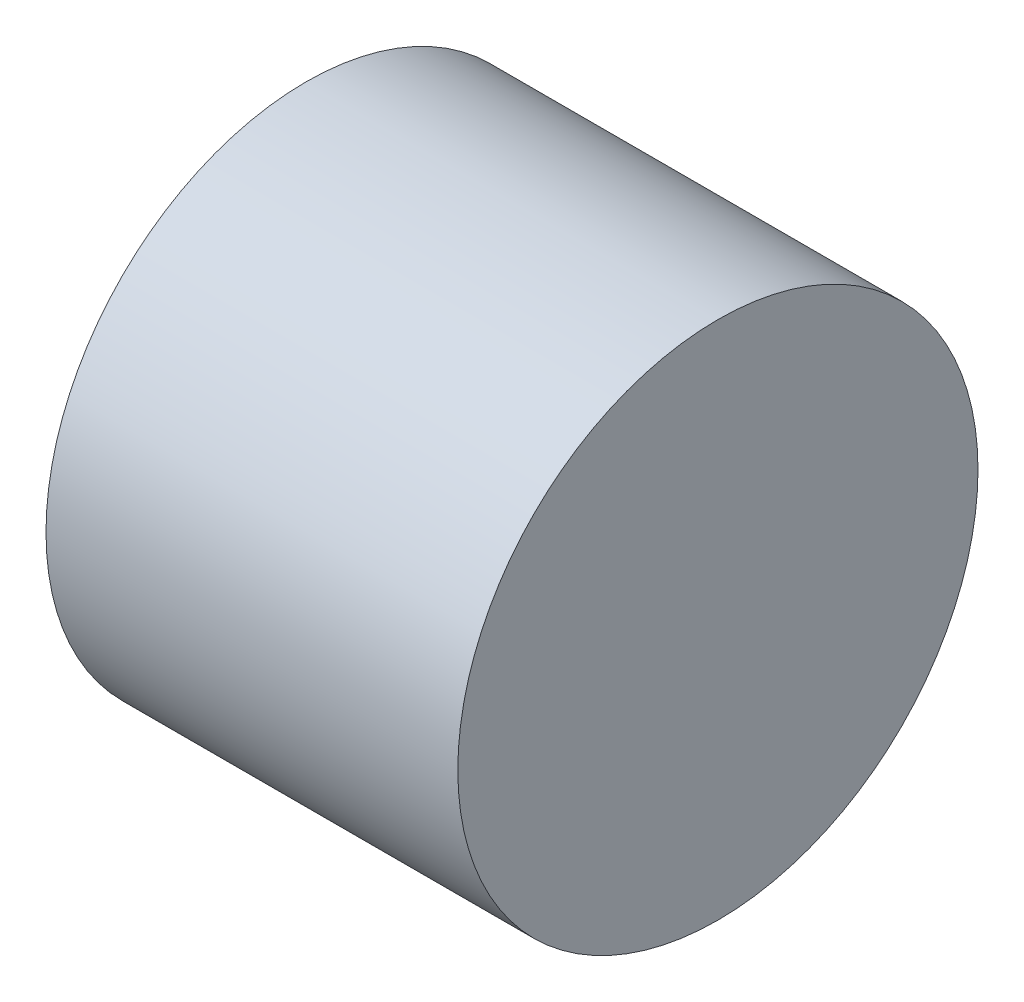
from build123d import *

# Parameters (mm, degrees)
SKETCH1_R           = 6
BOSS_EXTRUDE1_DEPTH = 9.5
SCALE1_SCALE        = 25.4


with BuildPart() as part:
    # Sketch1 → Boss-Extrude1 (new body)
    with BuildSketch(Plane(origin=(0, 0, 0), x_dir=(0, 0, -1), z_dir=(1, 0, 0))):
        Circle(SKETCH1_R)
    extrude(amount=BOSS_EXTRUDE1_DEPTH)


with BuildPart() as part_1:
    # Scale1: scaled about (4.75, 0, 0)
    add(part.part.scale(SCALE1_SCALE).moved(Location((-115.9, 0, 0))))


solid = part_1.part
